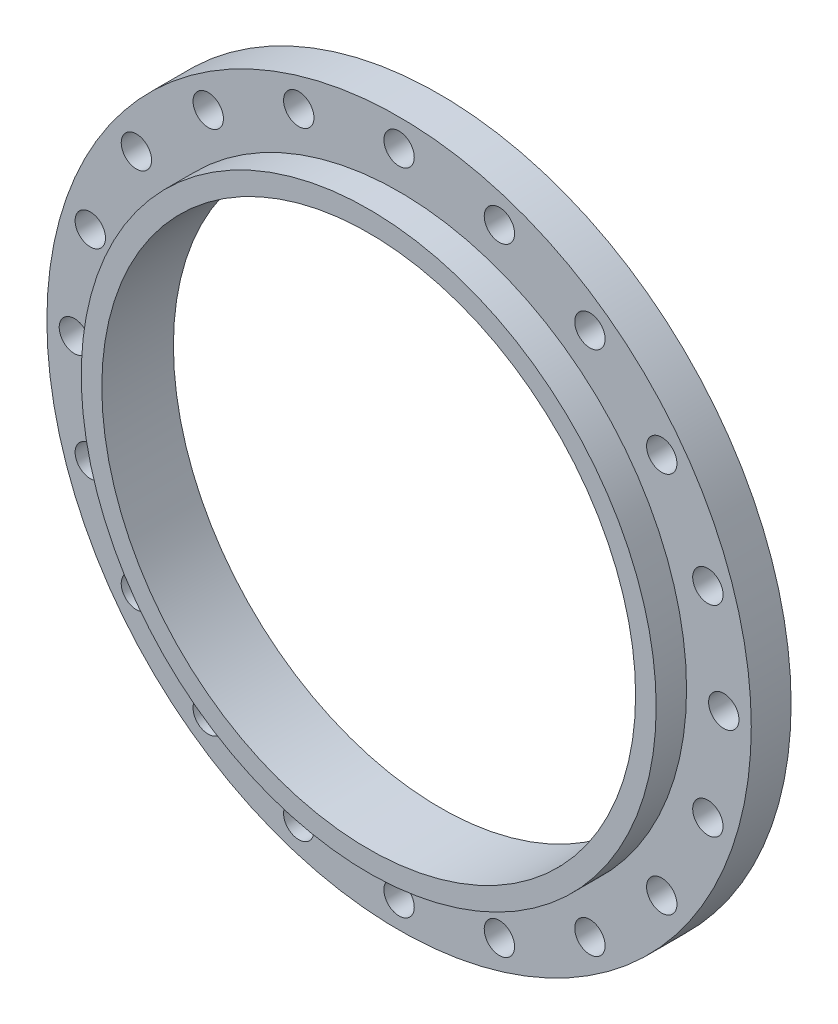
from build123d import *

# Parameters (mm, degrees)
SKETCH2_R               = 16
BOSS_EXTRUDE1_DEPTH     = 1.81
SKETCH3_R               = 13.06
BOSS_EXTRUDE2_DEPTH     = 3.19
SKETCH4_R               = 13.625
BOSS_EXTRUDE3_DEPTH     = 0.0625
SKETCH5_R               = 12.125
CUT_EXTRUDE1_DEPTH      = 56
CUT_EXTRUDE1_DEPTH_BACK = 4.0625
SKETCH6_R               = 0.69
CUT_EXTRUDE2_DEPTH      = 2.0625
CIRPATTERN1_COUNT       = 20
SCALE1_SCALE            = 25.4


with BuildPart() as part:
    # Sketch2 → Boss-Extrude1 (new body)
    with BuildSketch(Plane.XY):
        Circle(SKETCH2_R)
    extrude(amount=BOSS_EXTRUDE1_DEPTH)

    # Sketch3 → Boss-Extrude2 (add)
    with BuildSketch(Plane.XY):
        Circle(SKETCH3_R)
    extrude(amount=BOSS_EXTRUDE2_DEPTH)

    # Sketch4 → Boss-Extrude3 (add)
    with BuildSketch(Plane.XY):
        Circle(SKETCH4_R)
    extrude(amount=-BOSS_EXTRUDE3_DEPTH)

    # Sketch5 → Cut-Extrude1 (cut, two sides)
    with BuildSketch(Plane.XY) as cut_extrude1_sk:
        Circle(SKETCH5_R)
    extrude(amount=CUT_EXTRUDE1_DEPTH, mode=Mode.SUBTRACT)
    extrude(cut_extrude1_sk.sketch, amount=-CUT_EXTRUDE1_DEPTH_BACK, mode=Mode.SUBTRACT)

    # Sketch6 → Cut-Extrude2 (cut)
    with BuildSketch(Plane.XY):
        with Locations((0, 14.75)):
            Circle(SKETCH6_R)
    cut_extrude2 = extrude(amount=CUT_EXTRUDE2_DEPTH, mode=Mode.SUBTRACT)

    # CirPattern1: Cut-Extrude2 ×20 about axis
    cirpattern1_axis = Axis((0, 0, 0), (0, 0, 1))
    for i in range(1, CIRPATTERN1_COUNT):
        add(cut_extrude2.rotate(cirpattern1_axis, i * 360 / CIRPATTERN1_COUNT), mode=Mode.SUBTRACT)


with BuildPart() as part_1:
    # Scale1: scaled about (0, 0, 1.135631503)
    add(part.part.scale(SCALE1_SCALE).moved(Location((0, 0, -27.709408673))))


solid = part_1.part
